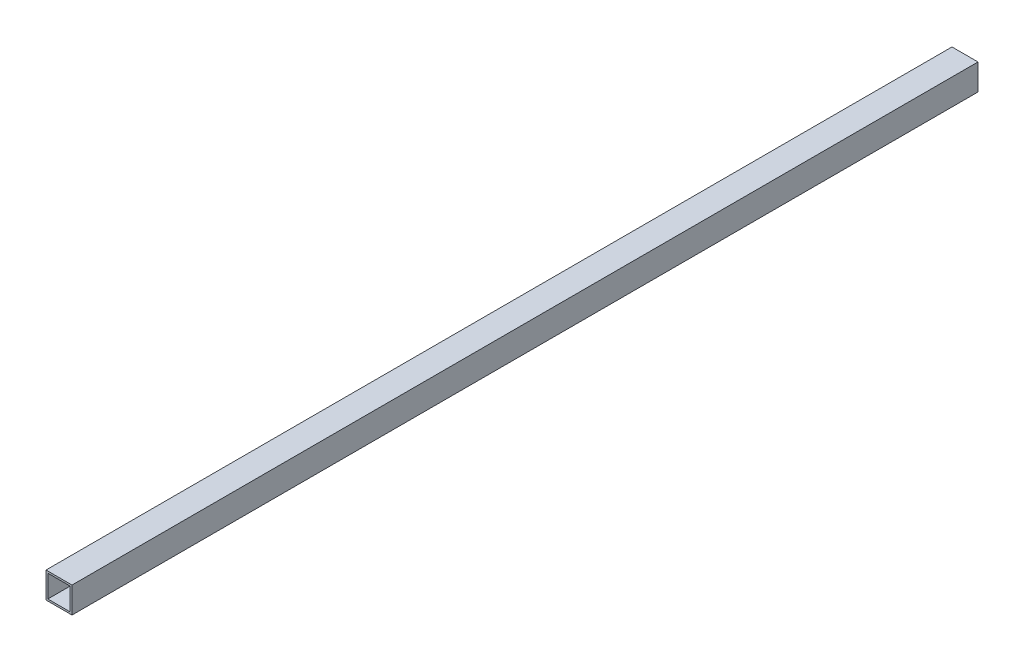
from build123d import *

# Parameters (mm, degrees)
SKETCH1_W           = 17
SKETCH1_H           = 17
SKETCH1_W_2         = 14.6
SKETCH1_H_2         = 14.6
BOSS_EXTRUDE1_DEPTH = 592


with BuildPart() as part:
    # Sketch1 → Boss-Extrude1 (new body)
    with BuildSketch(Plane.XY):
        Rectangle(SKETCH1_W, SKETCH1_H)
        Rectangle(SKETCH1_W_2, SKETCH1_H_2, mode=Mode.SUBTRACT)
    extrude(amount=BOSS_EXTRUDE1_DEPTH)


solid = part.part
